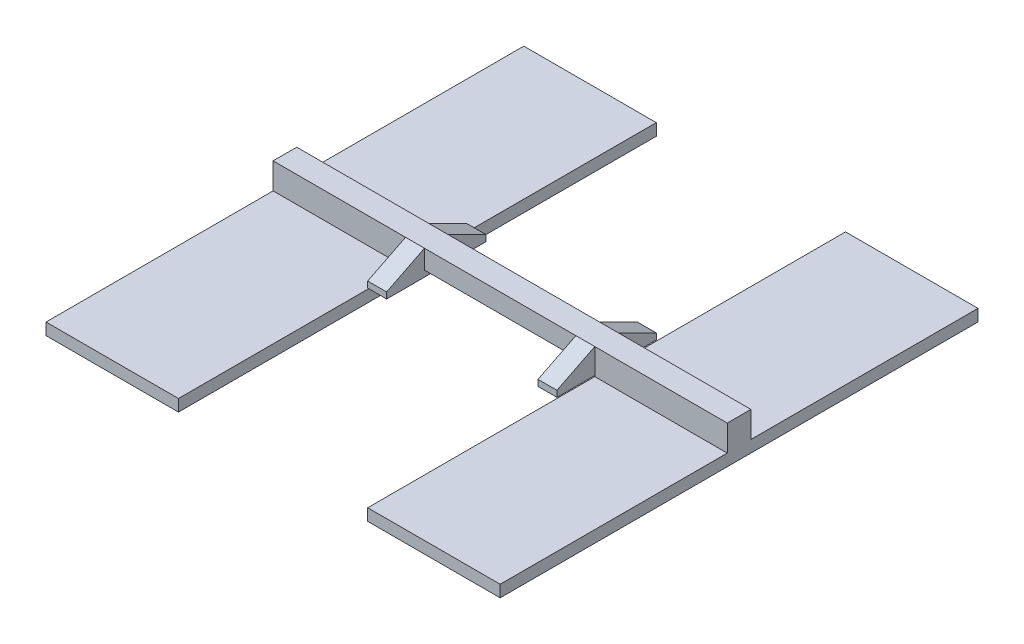
from build123d import *

# Parameters (mm, degrees)
BOSS_EXTRUDE1_DEPTH      = 1.25
SKETCH2_W                = 1
SKETCH2_H                = 0.325
BOSS_EXTRUDE2_DEPTH      = 2
SKETCH3_W                = 1
SKETCH3_H                = 0.325
BOSS_EXTRUDE3_DEPTH      = 2
BOSS_EXTRUDE7_DEPTH      = 1
BOSS_EXTRUDE8_DEPTH      = 1
SKETCH9_W                = 7
SKETCH9_H                = 0.624150965
BOSS_EXTRUDE9_DEPTH      = 12
BOSS_EXTRUDE9_DEPTH_BACK = 13.25


with BuildPart() as part:
    # Sketch1 → Boss-Extrude1 (new body)
    with BuildSketch(Plane.XY):
        Polygon((1, 0), (9, 0), (9, -0.325), (10, -0.325), (10, -1), (17, -1), (17, 1), (10, 1), (0, 1), (-7, 1), (-7, -1), (0, -1), (0, -0.325), (1, -0.325), align=None)
    extrude(amount=BOSS_EXTRUDE1_DEPTH)

    # Sketch2 → Boss-Extrude2 (add)
    with BuildSketch(Plane.XY.offset(1.25)):
        with Locations((0.5, -0.1625)):
            Rectangle(SKETCH2_W, SKETCH2_H)
        with Locations((9.5, -0.1625)):
            Rectangle(SKETCH2_W, SKETCH2_H)
    extrude(amount=BOSS_EXTRUDE2_DEPTH)

    # Sketch3 → Boss-Extrude3 (add)
    with BuildSketch(Plane(origin=(0, 0, 0), x_dir=(-1, 0, 0), z_dir=(0, 0, -1))):
        with Locations((-9.5, -0.1625)):
            Rectangle(SKETCH3_W, SKETCH3_H)
        with Locations((-0.5, -0.1625)):
            Rectangle(SKETCH3_W, SKETCH3_H)
    extrude(amount=BOSS_EXTRUDE3_DEPTH)

    # Sketch7 → Boss-Extrude7 (add)
    with BuildSketch(Plane(origin=(10, 0, 0), x_dir=(0, 0, -1), z_dir=(1, 0, 0))):
        Polygon((-3.25, 0), (-1.25, 1), (-1.25, 0), (-1.25, -0.325), (-3.25, -0.325), align=None)
        Polygon((2, 0), (0, 1), (0, 0), align=None)
    extrude(amount=-BOSS_EXTRUDE7_DEPTH)

    # Sketch8 → Boss-Extrude8 (add)
    with BuildSketch(Plane.ZY):
        Polygon((-2, 0), (0, 1), (0, 0), align=None)
        Polygon((1.25, 1), (1.25, 0), (3.25, 0), align=None)
    extrude(amount=-BOSS_EXTRUDE8_DEPTH)

    # Sketch9 → Boss-Extrude9 (add, two sides)
    with BuildSketch(Plane.XY.offset(1.25)) as boss_extrude9_sk:
        with Locations((-3.5, -0.687924517)):
            Rectangle(SKETCH9_W, SKETCH9_H)
        with Locations((13.5, -0.687924517)):
            Rectangle(SKETCH9_W, SKETCH9_H)
    extrude(amount=BOSS_EXTRUDE9_DEPTH)
    extrude(boss_extrude9_sk.sketch, amount=-BOSS_EXTRUDE9_DEPTH_BACK)


solid = part.part
